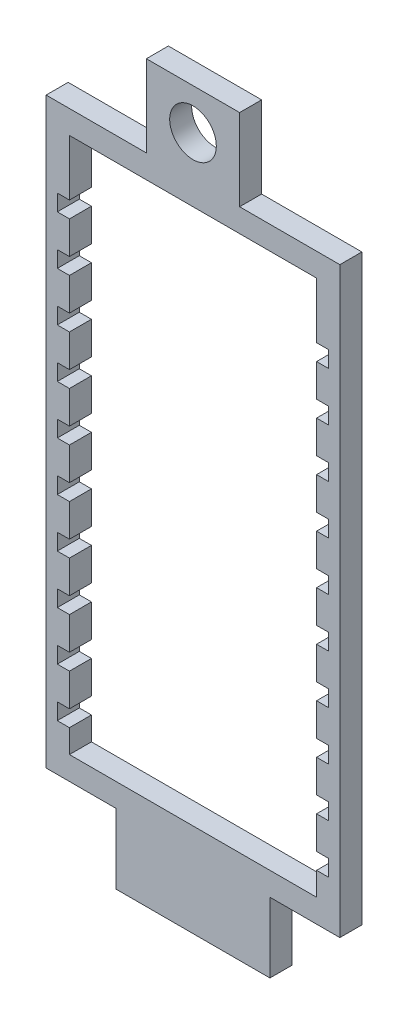
from build123d import *

# Parameters (mm, degrees)
SKETCH1_W           = 67.31
SKETCH1_H           = 146.05
BOSS_EXTRUDE1_DEPTH = 5.9944
SKETCH2_W           = 6.604
SKETCH2_H           = 4.445
CUT_EXTRUDE1_DEPTH  = 6.9944
SKETCH3_W           = 25.4
SKETCH3_H           = 22.225
SKETCH3_R           = 6.35
BOSS_EXTRUDE2_DEPTH = 5.9944


with BuildPart() as part:
    # Sketch1 → Boss-Extrude1 (new body)
    with BuildSketch(Plane.XY):
        Polygon((0, 19.05), (0, 177.8), (6.35, 177.8), (73.66, 177.8), (80.01, 177.8), (80.01, 19.05), (60.96, 19.05), (60.96, 0), (19.05, 0), (19.05, 19.05), align=None)
        with Locations((40.005, 98.425)):
            Rectangle(SKETCH1_W, SKETCH1_H, mode=Mode.SUBTRACT)
    extrude(amount=-BOSS_EXTRUDE1_DEPTH)

    # Sketch2 → Cut-Extrude1 (cut, through all)
    with BuildSketch(Plane.XY):
        with Locations((6.35, 33.9725)):
            Rectangle(SKETCH2_W, SKETCH2_H)
        with Locations((6.35, 47.3075)):
            Rectangle(SKETCH2_W, SKETCH2_H)
        with Locations((6.35, 60.6425)):
            Rectangle(SKETCH2_W, SKETCH2_H)
        with Locations((6.35, 73.9775)):
            Rectangle(SKETCH2_W, SKETCH2_H)
        with Locations((6.35, 87.3125)):
            Rectangle(SKETCH2_W, SKETCH2_H)
        with Locations((6.35, 100.6475)):
            Rectangle(SKETCH2_W, SKETCH2_H)
        with Locations((6.35, 113.9825)):
            Rectangle(SKETCH2_W, SKETCH2_H)
        with Locations((6.35, 127.3175)):
            Rectangle(SKETCH2_W, SKETCH2_H)
        with Locations((6.35, 140.6525)):
            Rectangle(SKETCH2_W, SKETCH2_H)
        with Locations((6.35, 153.9875)):
            Rectangle(SKETCH2_W, SKETCH2_H)
        with Locations((73.66, 153.9875)):
            Rectangle(SKETCH2_W, SKETCH2_H)
        with Locations((73.66, 140.6525)):
            Rectangle(SKETCH2_W, SKETCH2_H)
        with Locations((73.66, 127.3175)):
            Rectangle(SKETCH2_W, SKETCH2_H)
        with Locations((73.66, 113.9825)):
            Rectangle(SKETCH2_W, SKETCH2_H)
        with Locations((73.66, 100.6475)):
            Rectangle(SKETCH2_W, SKETCH2_H)
        with Locations((73.66, 87.3125)):
            Rectangle(SKETCH2_W, SKETCH2_H)
        with Locations((73.66, 73.9775)):
            Rectangle(SKETCH2_W, SKETCH2_H)
        with Locations((73.66, 60.6425)):
            Rectangle(SKETCH2_W, SKETCH2_H)
        with Locations((73.66, 47.3075)):
            Rectangle(SKETCH2_W, SKETCH2_H)
        with Locations((73.66, 33.9725)):
            Rectangle(SKETCH2_W, SKETCH2_H)
    extrude(amount=-CUT_EXTRUDE1_DEPTH, mode=Mode.SUBTRACT)

    # Sketch3 → Boss-Extrude2 (add)
    with BuildSketch(Plane.XY):
        with Locations((40.005, 188.9125)):
            Rectangle(SKETCH3_W, SKETCH3_H)
        with Locations((40.005, 188.9125)):
            Circle(SKETCH3_R, mode=Mode.SUBTRACT)
    extrude(amount=-BOSS_EXTRUDE2_DEPTH)


solid = part.part
